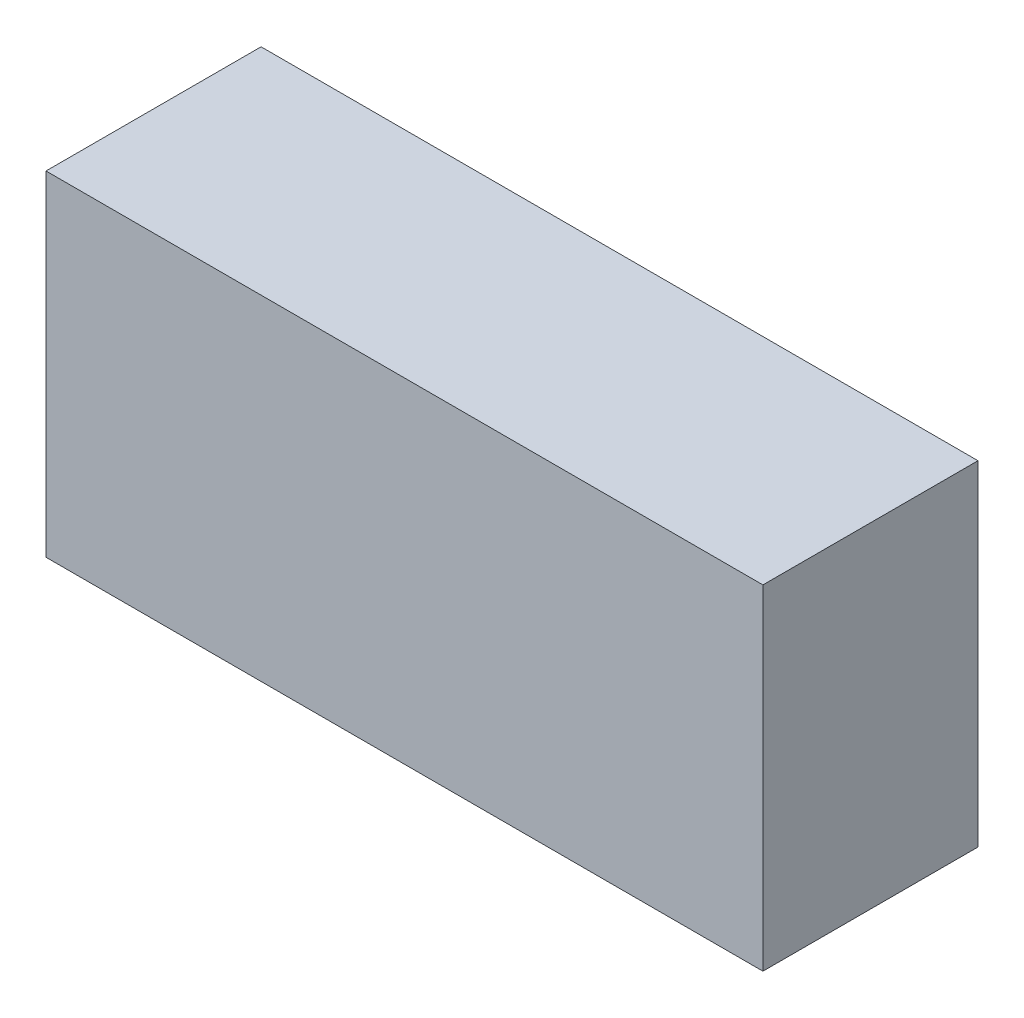
from build123d import *

# Parameters (mm, degrees)
SKETCH_1_W      = 150
SKETCH_1_H      = 70
EXTRUDE_1_DEPTH = 45


with BuildPart() as part:
    # Эскиз1 → Бобышка-Вытянуть1 (new body)
    with BuildSketch(Plane.XY):
        with Locations((75, 35)):
            Rectangle(SKETCH_1_W, SKETCH_1_H)
    extrude(amount=EXTRUDE_1_DEPTH)


solid = part.part
